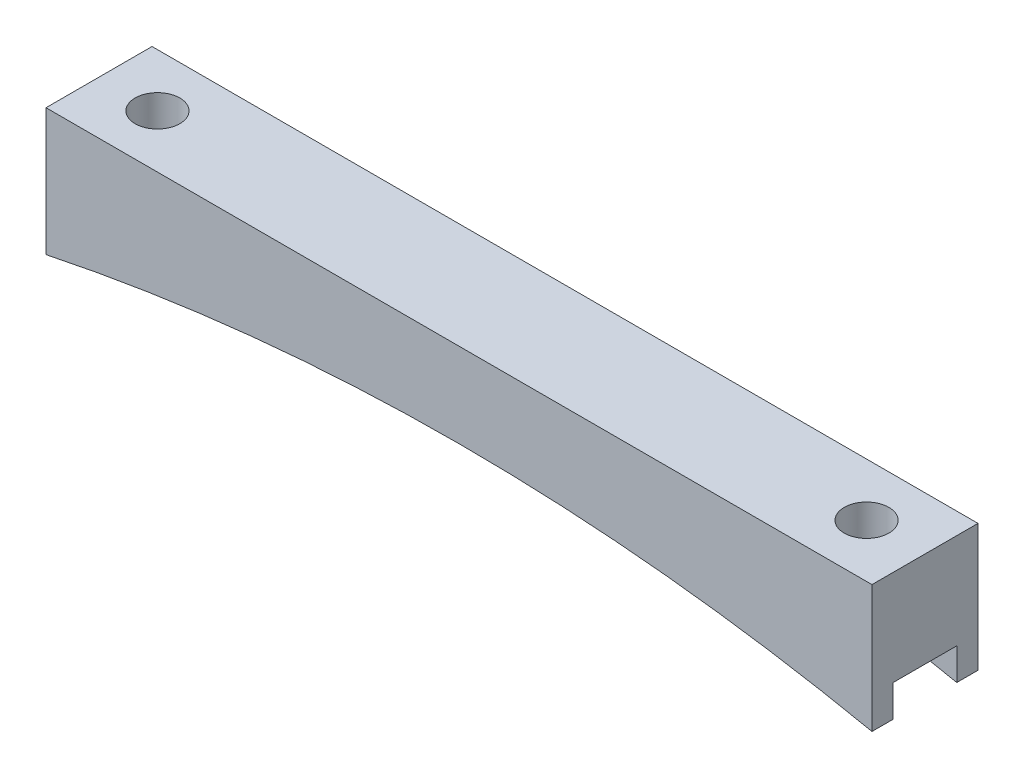
from build123d import *

# Parameters (mm, degrees)
BOSS_EXTRUDE1_DEPTH = 12.7
SKETCH2_R           = 2.675
CUT_EXTRUDE1_DEPTH  = 16.24
SKETCH3_W           = 7.62
SKETCH3_H           = 3.81
CUT_EXTRUDE2_DEPTH  = 99.9300001


with BuildPart() as part:
    # Sketch1 → Boss-Extrude1 (new body)
    with BuildSketch(Plane.XY):
        with BuildLine():
            Line((-49.465, 0), (49.465, 0))
            Line((49.465, 0), (49.465, -15.24))
            ThreePointArc((49.465, -15.24), (0, -10.115578278), (-49.465, -15.24))
            Line((-49.465, -15.24), (-49.465, 0))
        make_face()
    extrude(amount=BOSS_EXTRUDE1_DEPTH)

    # Sketch2 → Cut-Extrude1 (cut, through all)
    with BuildSketch(Plane(origin=(0, 0, 0), x_dir=(1, 0, 0), z_dir=(0, 1, 0))):
        with Locations((-42.465, -6.35)):
            Circle(SKETCH2_R)
        with Locations((42.465, -6.35)):
            Circle(SKETCH2_R)
    extrude(amount=-CUT_EXTRUDE1_DEPTH, mode=Mode.SUBTRACT)

    # Sketch3 → Cut-Extrude2 (cut, through all)
    with BuildSketch(Plane(origin=(49.465, 0, 0), x_dir=(0, 0, -1), z_dir=(1, 0, 0))):
        with Locations((-6.35, -13.335)):
            Rectangle(SKETCH3_W, SKETCH3_H)
    extrude(amount=-CUT_EXTRUDE2_DEPTH, mode=Mode.SUBTRACT)


solid = part.part
